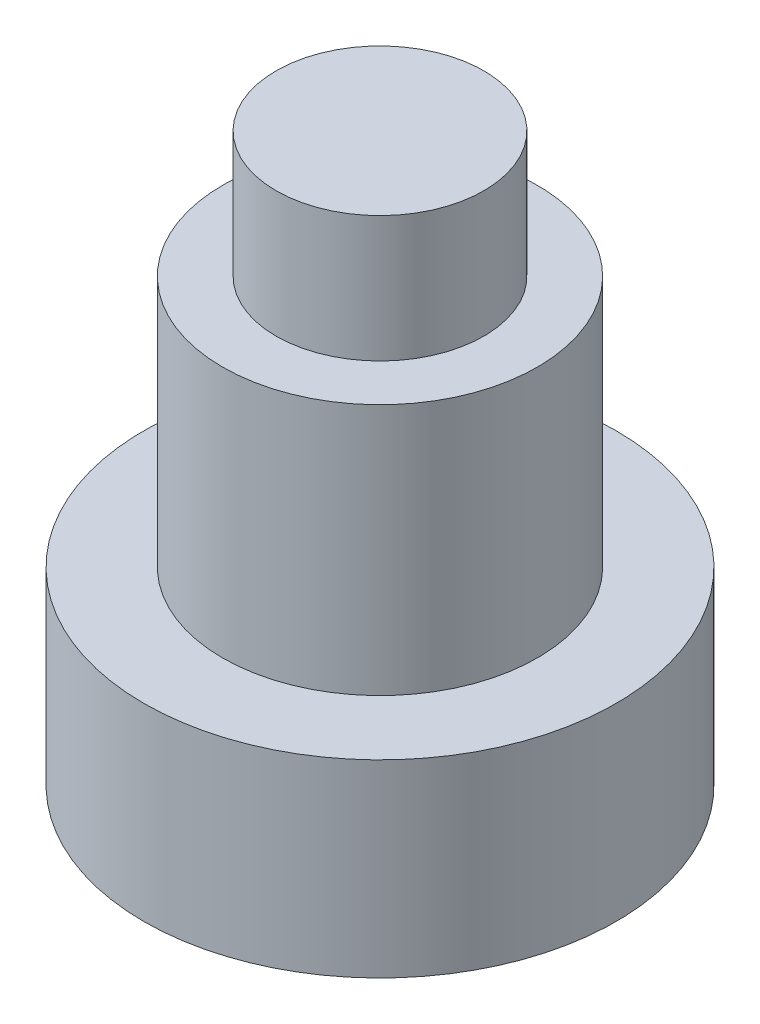
from build123d import *

# Parameters (mm, degrees)
SKETCH1_R           = 3.75
BOSS_EXTRUDE1_DEPTH = 7
SKETCH2_R           = 3.75
SKETCH2_R_2         = 2.5
CUT_EXTRUDE1_DEPTH  = 4
SKETCH3_R           = 1.65
BOSS_EXTRUDE2_DEPTH = 2


with BuildPart() as part:
    # Sketch1 → Boss-Extrude1 (new body)
    with BuildSketch(Plane(origin=(0, 0, 0), x_dir=(1, 0, 0), z_dir=(0, 1, 0))):
        Circle(SKETCH1_R)
    extrude(amount=BOSS_EXTRUDE1_DEPTH)

    # Sketch2 → Cut-Extrude1 (cut)
    with BuildSketch(Plane(origin=(0, 7, 0), x_dir=(1, 0, 0), z_dir=(0, 1, 0))):
        Circle(SKETCH2_R)
        Circle(SKETCH2_R_2, mode=Mode.SUBTRACT)
    extrude(amount=-CUT_EXTRUDE1_DEPTH, mode=Mode.SUBTRACT)

    # Sketch3 → Boss-Extrude2 (add)
    with BuildSketch(Plane(origin=(0, 7, 0), x_dir=(1, 0, 0), z_dir=(0, 1, 0))):
        Circle(SKETCH3_R)
    extrude(amount=BOSS_EXTRUDE2_DEPTH)


solid = part.part
